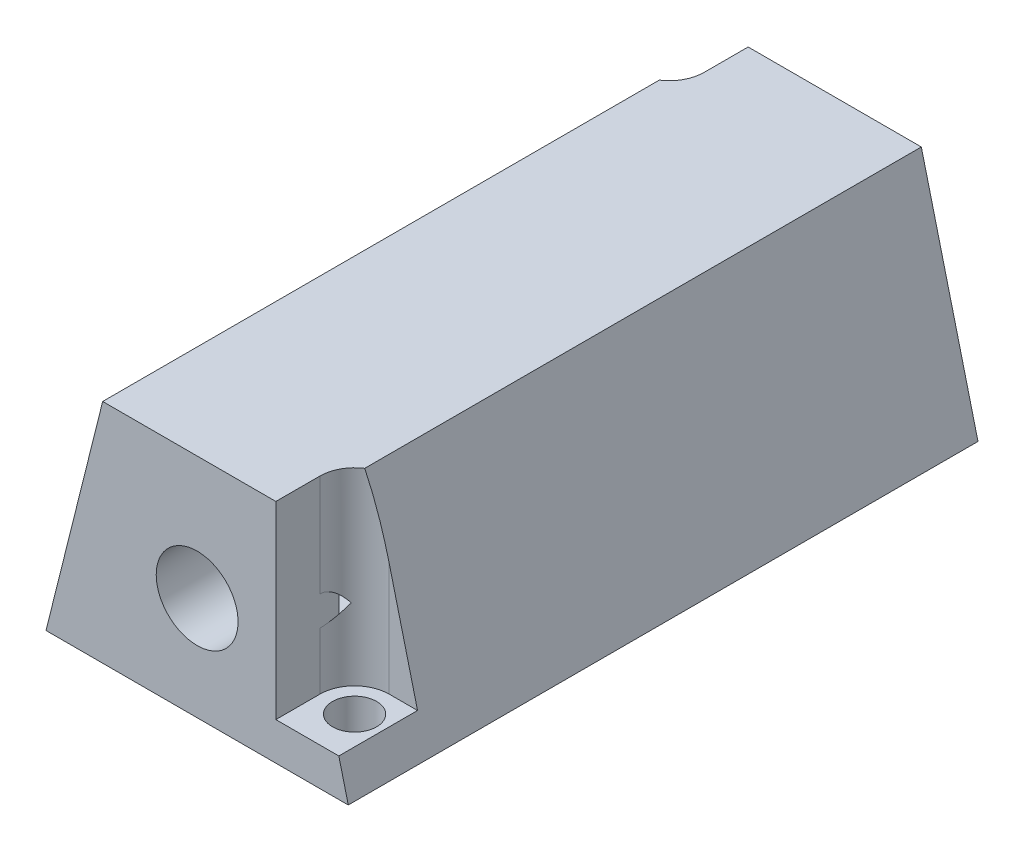
from build123d import *

# Parameters (mm, degrees)
SALIENTE_EXTRUIR1_DEPTH = 50
CROQUIS3_R              = 1.75
CORTAR_EXTRUIR1_DEPTH   = 50
CORTAR_EXTRUIR2_DEPTH   = 50
CROQUIS5_W              = 13.75
CROQUIS5_H              = 15.668518787
SALIENTE_EXTRUIR2_DEPTH = 5
CROQUIS6_R              = 3.25
CORTAR_EXTRUIR3_DEPTH   = 51


with BuildPart() as part:
    # Croquis1 → Saliente-Extruir1 (new body)
    with BuildSketch(Plane.XY):
        Polygon((-11.139985082, 4.35106383), (12.860014918, 4.35106383), (8.360014918, 22.35106383), (-6.639985082, 22.35106383), align=None)
        Polygon((-6.068188312, 13.064935956), (-2.604086697, 7.064935956), (4.324116534, 7.064935956), (7.788218149, 13.064935956), (4.324116534, 19.064935956), (-2.604086697, 19.064935956), align=None, mode=Mode.SUBTRACT)
    extrude(amount=SALIENTE_EXTRUIR1_DEPTH)

    # Croquis3 → Cortar-Extruir1 (cut)
    with BuildSketch(Plane.XZ.offset(-4.35106383)):
        with Locations((-8.139985082, 3.5)):
            Circle(CROQUIS3_R)
        with Locations((9.860014918, 46.5)):
            Circle(CROQUIS3_R)
    extrude(amount=-CORTAR_EXTRUIR1_DEPTH, mode=Mode.SUBTRACT)

    # Croquis4 → Cortar-Extruir2 (cut)
    with BuildSketch(Plane(origin=(0, 7.35106383, 0), x_dir=(-1, 0, 0), z_dir=(0, -1, 0))):
        with BuildLine():
            Line((-18.110014918, -43.75), (-9.860014918, -43.75))
            ThreePointArc((-9.860014918, -43.75), (-7.91547127, -44.555456352), (-7.110014918, -46.5))
            Line((-7.110014918, -46.5), (-7.110014918, -54.75))
            Line((-7.110014918, -54.75), (-18.110014918, -54.75))
            Line((-18.110014918, -54.75), (-18.110014918, -43.75))
        make_face()
        with BuildLine():
            Line((16.389985082, -6.25), (8.139985082, -6.25))
            ThreePointArc((8.139985082, -6.25), (6.195441433, -5.444543648), (5.389985082, -3.5))
            Line((5.389985082, -3.5), (5.389985082, 4.75))
            Line((5.389985082, 4.75), (16.389985082, 4.75))
            Line((16.389985082, 4.75), (16.389985082, -6.25))
        make_face()
    extrude(amount=-CORTAR_EXTRUIR2_DEPTH, mode=Mode.SUBTRACT)

    # Croquis5 → Saliente-Extruir2 (add)
    with BuildSketch(Plane.XY.offset(50)):
        with Locations((0.235014918, 14.516804437)):
            Rectangle(CROQUIS5_W, CROQUIS5_H)
    extrude(amount=-SALIENTE_EXTRUIR2_DEPTH)

    # Croquis6 → Cortar-Extruir3 (cut, through all)
    with BuildSketch(Plane(origin=(0, 0, 0), x_dir=(-1, 0, 0), z_dir=(0, 0, -1))):
        with Locations((-0.860014918, 12.564935956)):
            Circle(CROQUIS6_R)
    extrude(amount=-CORTAR_EXTRUIR3_DEPTH, mode=Mode.SUBTRACT)


solid = part.part
